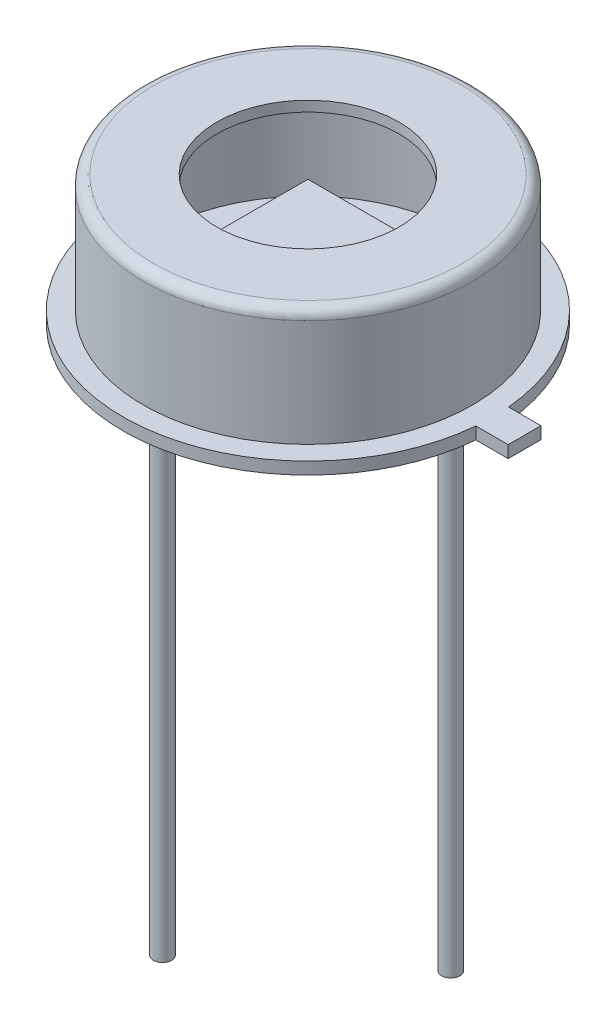
from build123d import *

# Parameters (mm, degrees)
SKETCH2_R           = 4.57
BOSS_EXTRUDE1_DEPTH = 0.046
BOSS_EXTRUDE2_START = -1.8
SKETCH3_W           = 2.5
SKETCH3_H           = 2.5
BOSS_EXTRUDE2_DEPTH = 0.05
SKETCH8_W           = 2.2
SKETCH8_H           = 2.2
BOSS_EXTRUDE6_DEPTH = 0.2
BOSS_EXTRUDE8_DEPTH = 0.3
SKETCH5_R           = 0.225
BOSS_EXTRUDE4_DEPTH = 13.5


with BuildPart() as part:
    # Sketch1 → Revolve-Thin2 (revolve)
    with BuildSketch(Plane.XY, mode=Mode.PRIVATE) as revolve_thin2_sk:
        with BuildLine():
            Line((4.57, 0), (4.57, 0.3))
            Line((4.57, 0.3), (4.065, 0.3))
            Line((4.065, 0.3), (4.065, 2.946))
            ThreePointArc((4.065, 2.946), (3.990605122, 3.125605122), (3.811, 3.2))
            Line((3.811, 3.2), (2.25, 3.2))
            Line((2.25, 3.2), (2.25, 2.946))
            Line((2.25, 2.946), (3.811, 2.946))
            Line((3.811, 2.946), (3.811, 0.046))
            Line((3.811, 0.046), (4.316, 0.046))
            Line((4.316, 0.046), (4.316, 0))
            Line((4.316, 0), (4.57, 0))
        make_face()
    revolve(revolve_thin2_sk.sketch.rotate(Axis((0, 0, 0), (0, 1, 0)), 90), axis=Axis((0, 0, 0), (0, 1, 0)))  # turned: the seam where the file's is

    # Sketch2 → Boss-Extrude1 (add)
    with BuildSketch(Plane.XZ):
        with Locations(Location((0, 0, 0), (0, 0, 270))):  # turned: the seam where the file's is
            Circle(SKETCH2_R)
    extrude(amount=-BOSS_EXTRUDE1_DEPTH)

    # Sketch11 → Boss-Extrude8 (add)
    with BuildSketch(Plane.XZ):
        with BuildLine():
            Line((5.352018783, -0.405), (5.352018783, 0))
            Line((5.352018783, 0), (5.352018783, 0.405))
            Line((5.352018783, 0.405), (4.552018783, 0.405))
            ThreePointArc((4.552018783, 0.405), (4.565502483, 0.202699485), (4.57, 0))
            ThreePointArc((4.57, 0), (4.565502483, -0.202699485), (4.552018783, -0.405))
            Line((4.552018783, -0.405), (5.352018783, -0.405))
        make_face()
    extrude(amount=-BOSS_EXTRUDE8_DEPTH)

    # Sketch5 → Boss-Extrude4 (add)
    with BuildSketch(Plane.XZ):
        with Locations(Location((2.096051224, -1.434632101, 0), (0, 0, 90))):  # turned: the seam where the file's is
            Circle(SKETCH5_R)
        with Locations(Location((-1.796051224, 1.796051224, 0), (0, 0, 90))):  # turned: the seam where the file's is
            Circle(SKETCH5_R)
    extrude(amount=BOSS_EXTRUDE4_DEPTH)


with BuildPart() as body_2:
    # Sketch3 → Boss-Extrude2 (new body)
    with BuildSketch(Plane.XZ.offset(BOSS_EXTRUDE2_START)):
        Rectangle(SKETCH3_W, SKETCH3_H)
    extrude(amount=BOSS_EXTRUDE2_DEPTH)

    # Sketch8 → Boss-Extrude6 (add)
    with BuildSketch(Plane(origin=(0, 1.8, 0), x_dir=(-1, 0, 0), z_dir=(0, 1, 0))):
        Rectangle(SKETCH8_W, SKETCH8_H)
    extrude(amount=BOSS_EXTRUDE6_DEPTH)


solid = Compound([part.part, body_2.part])
